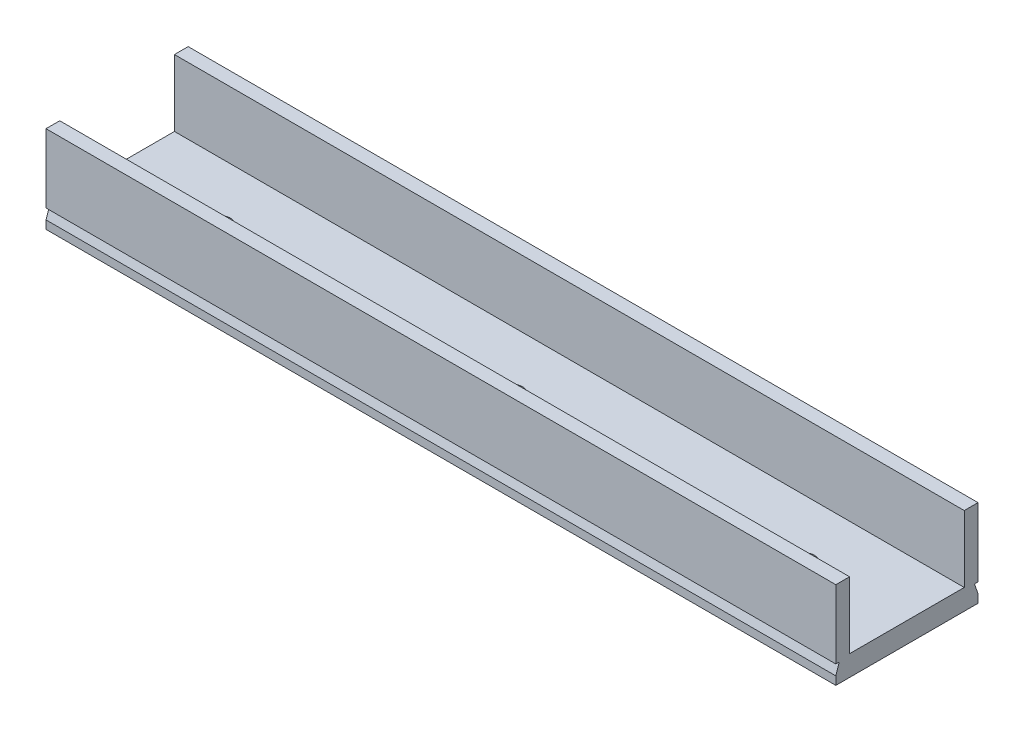
from build123d import *

# Parameters (mm, degrees)
CROQUIS1_W              = 115
CROQUIS1_H              = 20.7
SALIENTE_EXTRUIR2_DEPTH = 3
CROQUIS6_R              = 1.5
CORTAR_EXTRUIR4_DEPTH   = 3
CROQUIS7_W              = 115
CROQUIS7_H              = 2
SALIENTE_EXTRUIR3_DEPTH = 9.7
CORTAR_EXTRUIR5_DEPTH   = 224


with BuildPart() as part:
    # Croquis1 → Saliente-Extruir2 (new body)
    with BuildSketch(Plane(origin=(0, 0, 0), x_dir=(1, 0, 0), z_dir=(0, 1, 0))):
        Rectangle(CROQUIS1_W, CROQUIS1_H)
    extrude(amount=SALIENTE_EXTRUIR2_DEPTH)

    # Croquis6 → Cortar-Extruir4 (cut)
    with BuildSketch(Plane(origin=(0, 3, 0), x_dir=(1, 0, 0), z_dir=(0, 1, 0))):
        with Locations((-42.5, 0)):
            Circle(CROQUIS6_R)
        Circle(CROQUIS6_R)
        with Locations((42.5, 0)):
            Circle(CROQUIS6_R)
    extrude(amount=-CORTAR_EXTRUIR4_DEPTH, mode=Mode.SUBTRACT)

    # Croquis7 → Saliente-Extruir3 (add)
    with BuildSketch(Plane(origin=(0, 3, 0), x_dir=(1, 0, 0), z_dir=(0, 1, 0))):
        with Locations((0, 9.35)):
            Rectangle(CROQUIS7_W, CROQUIS7_H)
        with Locations((0, -9.35)):
            Rectangle(CROQUIS7_W, CROQUIS7_H)
    extrude(amount=SALIENTE_EXTRUIR3_DEPTH)

    # Croquis9 → Cortar-Extruir5 (cut)
    with BuildSketch(Plane.ZY.offset(57.5)):
        Polygon((-10.35, 2.7), (-9.85, 2.7), (-10.35, 1.2), align=None)
        Polygon((10.35, 2.7), (9.85, 2.7), (10.35, 1.2), align=None)
    extrude(amount=-CORTAR_EXTRUIR5_DEPTH, mode=Mode.SUBTRACT)


solid = part.part
